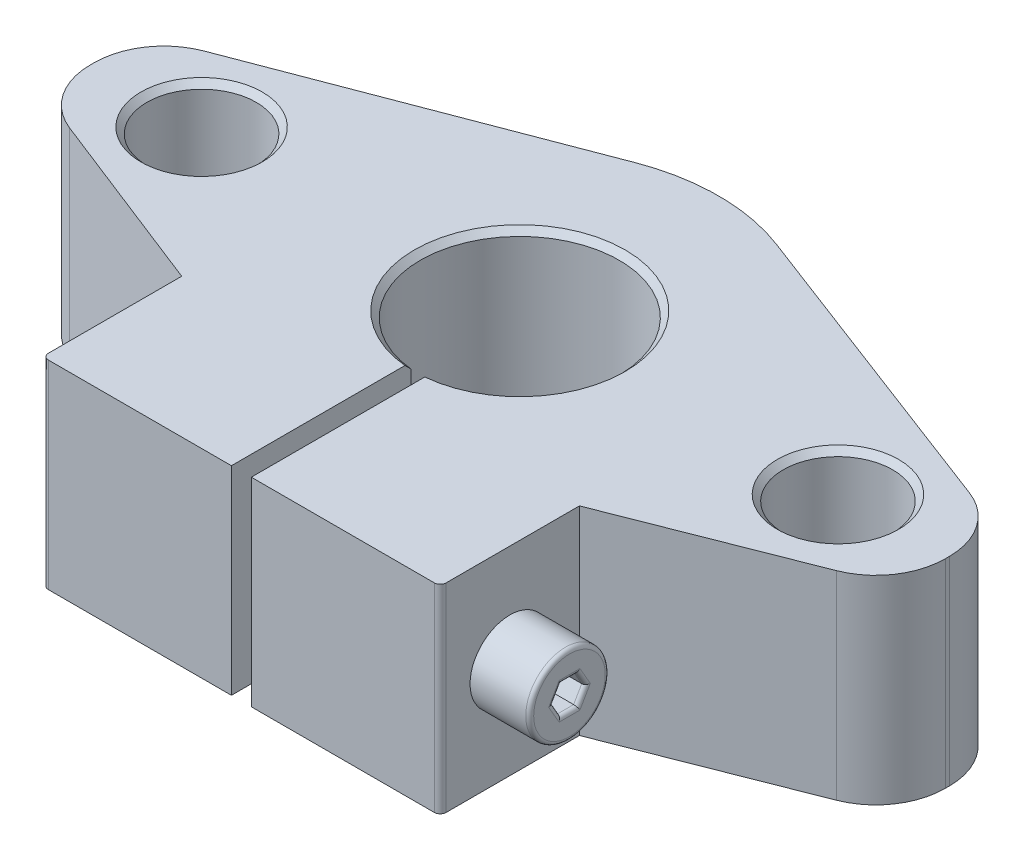
from build123d import *

# Parameters (mm, degrees)
SKETCH1_R                     = 2.75
BOSS_EXTRUDE1_DEPTH           = 10
SKETCH3_R                     = 2
CUT_EXTRUDE1_DEPTH            = 32.5
ESBO_O1_R                     = 2
RESSALTO_EXTRUS_O2_DEPTH      = 13
RESSALTO_EXTRUS_O2_DEPTH_BACK = 3
CORTE_EXTRUS_O1_DEPTH         = 5
FILETE1_R                     = 0.2
FILETE2_R                     = 0.25
CHAMFER_1_SIZE                = 0.3
FILLET_1_R                    = 0.3


with BuildPart() as part:
    # Sketch1 → Boss-Extrude1 (new body)
    with BuildSketch(Plane(origin=(0, 0, 0), x_dir=(1, 0, 0), z_dir=(0, 1, 0))):
        with BuildLine():
            Line((21.5, 0.100660355), (21.5, -0.100660355))
            ThreePointArc((21.5, -0.100660355), (20.891804651, -2.072326113), (19.278590937, -3.35875876))
            Line((19.278590937, -3.35875876), (10, -7))
            Line((10, -7), (10, -14))
            Line((10, -14), (0.5, -14))
            Line((0.5, -14), (0.5, -4.974937186))
            ThreePointArc((0.5, -4.974937186), (0, 5), (-0.5, -4.974937186))
            Line((-0.5, -4.974937186), (-0.5, -14))
            Line((-0.5, -14), (-10, -14))
            Line((-10, -14), (-10, -7))
            Line((-10, -7), (-19.278590937, -3.35875876))
            ThreePointArc((-19.278590937, -3.35875876), (-20.891804651, -2.072326113), (-21.5, -0.100660355))
            Line((-21.5, -0.100660355), (-21.5, 0.100660355))
            ThreePointArc((-21.5, 0.100660355), (-20.881804225, 2.086914218), (-19.245597481, 3.371514512))
            Line((-19.245597481, 3.371514512), (-3.558849946, 9.345297591))
            ThreePointArc((-3.558849946, 9.345297591), (0, 10), (3.558849946, 9.345297591))
            Line((3.558849946, 9.345297591), (19.245597481, 3.371514512))
            ThreePointArc((19.245597481, 3.371514512), (20.881804225, 2.086914218), (21.5, 0.100660355))
        make_face()
        with Locations(Location((-16, 0, 0), (0, 0, 270))):  # turned: the seam where the file's is
            Circle(SKETCH1_R, mode=Mode.SUBTRACT)
        with Locations(Location((16, 0, 0), (0, 0, 270))):  # turned: the seam where the file's is
            Circle(SKETCH1_R, mode=Mode.SUBTRACT)
    extrude(amount=BOSS_EXTRUDE1_DEPTH)

    # Sketch3 → Cut-Extrude1 (cut, through all)
    with BuildSketch(Plane(origin=(10, 0, 0), x_dir=(0, 0, -1), z_dir=(1, 0, 0))):
        with Locations((-10.5, 5)):
            Circle(SKETCH3_R)
    extrude(amount=-CUT_EXTRUDE1_DEPTH, mode=Mode.SUBTRACT)

    # Esboço1 → Ressalto-extrusão2 (add, two sides)
    with BuildSketch(Plane.ZY.offset(-10)) as ressalto_extrus_o2_sk:
        with Locations(Location((10.5, 5, 0), (0, 0, 180))):  # turned: the seam where the file's is
            Circle(ESBO_O1_R)
    extrude(amount=RESSALTO_EXTRUS_O2_DEPTH)
    extrude(ressalto_extrus_o2_sk.sketch, amount=-RESSALTO_EXTRUS_O2_DEPTH_BACK)

    # Esboço2 → Corte-extrusão1 (cut)
    with BuildSketch(Plane.ZY.offset(-13)):
        Polygon((10.90776936, 4.293722751), (11.315538719, 5), (10.90776936, 5.706277249), (10.09223064, 5.706277249), (9.684461281, 5), (10.09223064, 4.293722751), align=None)
    extrude(amount=CORTE_EXTRUS_O1_DEPTH, mode=Mode.SUBTRACT)

    # Filete1
    filete1_edges = [part.edges().sort_by_distance(p)[0] for p in [
        (13, 5, 12.5),
        (13, 4.646861376, 11.11165404),
        (13, 4.293722751, 10.5),
        (13, 4.646861376, 9.88834596),
        (13, 5.353138624, 9.88834596),
        (13, 5.706277249, 10.5),
        (13, 5.353138624, 11.11165404),
    ]]
    fillet(filete1_edges, radius=FILETE1_R)

    # Filete2
    filete2_edges = [part.edges().sort_by_distance(p)[0] for p in [
        (-3, 5, 12.5),
    ]]
    fillet(filete2_edges, radius=FILETE2_R)

    # Фаска1
    chamfer_1_edges = [part.edges().sort_by_distance(p)[0] for p in [
        (0, 0, -5),
        (-16, 0, -2.75),
        (0, 10, -5),
        (-16, 10, -2.75),
        (16, 0, -2.75),
        (16, 10, -2.75),
    ]]
    chamfer(chamfer_1_edges, length=CHAMFER_1_SIZE)

    # Скругление1
    fillet_1_edges = [part.edges().sort_by_distance(p)[0] for p in [
        (10, 5, 14),
        (-10, 5, 14),
    ]]
    fillet(fillet_1_edges, radius=FILLET_1_R)


solid = part.part
